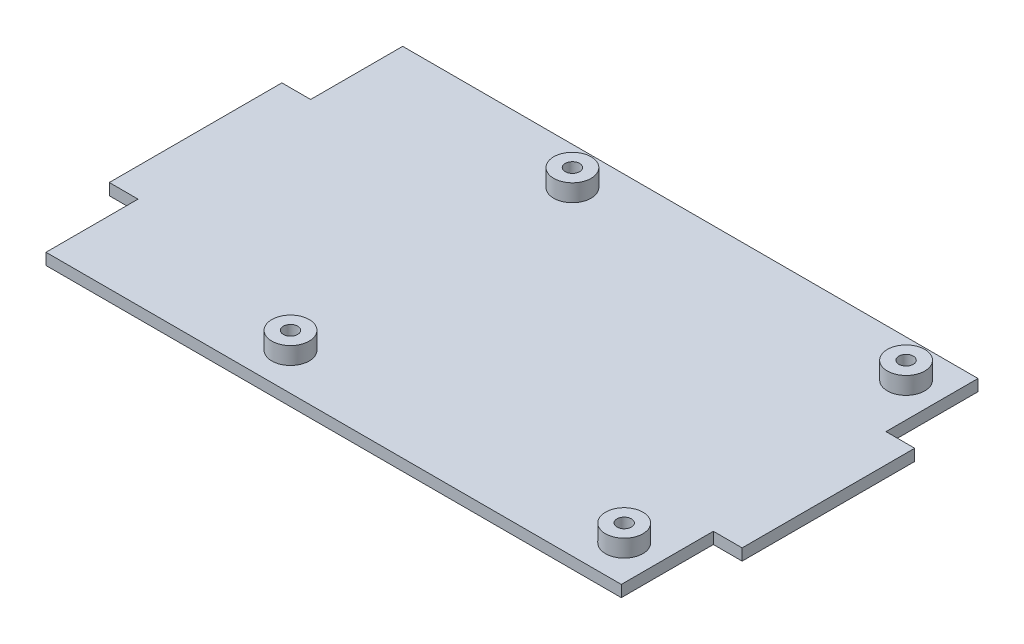
from build123d import *

# Parameters (mm, degrees)
SKETCH_1_W            = 100
SKETCH_1_H            = 62
SKETCH_1_W_2          = 110
SKETCH_1_H_2          = 30
EXTRUDE_467_DEPTH     = 2
SKETCH_2_R            = 1.25
CUT_EXTRUDE_872_DEPTH = 2
SKETCH_3_R            = 3.25
SKETCH_3_R_2          = 1.25
EXTRUDE_1188_DEPTH    = 3


with BuildPart() as part:
    # 草图1 → Extrude 467 (new body)
    with BuildSketch(Plane(origin=(0, 0, 0), x_dir=(1, 0, 0), z_dir=(0, 1, 0))):
        Rectangle(SKETCH_1_W, SKETCH_1_H)
        Rectangle(SKETCH_1_W_2, SKETCH_1_H_2)
    extrude(amount=EXTRUDE_467_DEPTH)

    # 草图2 → Cut-Extrude 872 (cut)
    with BuildSketch(Plane(origin=(0, 2, 0), x_dir=(1, 0, 0), z_dir=(0, 1, 0))):
        with Locations((-14, 24.5)):
            Circle(SKETCH_2_R)
        with Locations((44, 24.5)):
            Circle(SKETCH_2_R)
        with Locations((-14, -24.5)):
            Circle(SKETCH_2_R)
        with Locations((44, -24.5)):
            Circle(SKETCH_2_R)
    extrude(amount=-CUT_EXTRUDE_872_DEPTH, mode=Mode.SUBTRACT)

    # 草图3 → Extrude 1188 (add)
    with BuildSketch(Plane(origin=(0, 2, 0), x_dir=(1, 0, 0), z_dir=(0, 1, 0))):
        with Locations((-14, 24.5)):
            Circle(SKETCH_3_R)
        with Locations((-14, 24.5)):
            Circle(SKETCH_3_R_2, mode=Mode.SUBTRACT)
        with Locations((44, 24.5)):
            Circle(SKETCH_3_R)
        with Locations((44, 24.5)):
            Circle(SKETCH_3_R_2, mode=Mode.SUBTRACT)
        with Locations((-14, -24.5)):
            Circle(SKETCH_3_R)
        with Locations((-14, -24.5)):
            Circle(SKETCH_3_R_2, mode=Mode.SUBTRACT)
        with Locations((44, -24.5)):
            Circle(SKETCH_3_R)
        with Locations((44, -24.5)):
            Circle(SKETCH_3_R_2, mode=Mode.SUBTRACT)
    extrude(amount=EXTRUDE_1188_DEPTH)


solid = part.part
